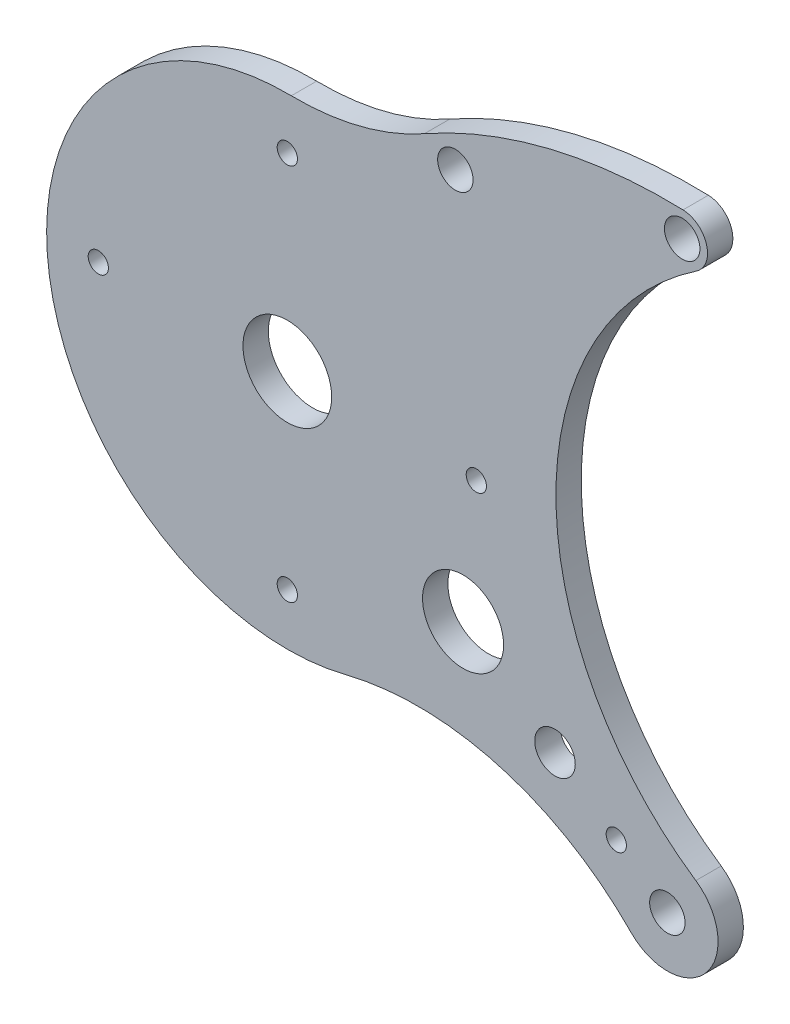
from build123d import *

# Parameters (mm, degrees)
SKETCH1_R           = 7
SKETCH1_R_2         = 4
SKETCH1_R_3         = 17.5
BOSS_EXTRUDE1_DEPTH = 10
SKETCH4_R           = 4
SKETCH4_R_2         = 8
SKETCH4_R_3         = 16
CUT_EXTRUDE1_DEPTH  = 11


with BuildPart() as part:
    # Sketch1 → Boss-Extrude1 (new body)
    with BuildSketch(Plane.XY):
        with BuildLine():
            ThreePointArc((1.572195793, 94.986989637), (-94.380567411, -10.83090463), (23.048944019, -92.161522229))
            ThreePointArc((23.048944019, -92.161522229), (83.617990825, -93.079348945), (135.711425994, -123.994164958))
            ThreePointArc((135.711425994, -123.994164958), (165.350102595, -122.820856068), (161.225161537, -93.447183066))
            ThreePointArc((161.225161537, -93.447183066), (106.014165413, 10.833093568), (161.441107802, 114.998751274))
            ThreePointArc((161.441107802, 114.998751274), (165.454566443, 126.056147345), (156.171848547, 133.281450563))
            ThreePointArc((156.171848547, 133.281450563), (103.433194213, 127.791254655), (54.122076862, 108.299676532))
            ThreePointArc((54.122076862, 108.299676532), (28.73316338, 98.145871106), (1.572195793, 94.986989637))
        make_face()
        with Locations((66.321036094, 102.089205288)):
            Circle(SKETCH1_R, mode=Mode.SUBTRACT)
        with Locations((155.845687485, 123.28677103)):
            Circle(SKETCH1_R, mode=Mode.SUBTRACT)
        with Locations((150, -110)):
            Circle(SKETCH1_R, mode=Mode.SUBTRACT)
        with Locations((0, 74.6)):
            Circle(SKETCH1_R_2, mode=Mode.SUBTRACT)
        with Locations((74.6, 0)):
            Circle(SKETCH1_R_2, mode=Mode.SUBTRACT)
        with Locations((0, -74.6)):
            Circle(SKETCH1_R_2, mode=Mode.SUBTRACT)
        with Locations((-74.6, 0)):
            Circle(SKETCH1_R_2, mode=Mode.SUBTRACT)
        Circle(SKETCH1_R_3, mode=Mode.SUBTRACT)
    extrude(amount=BOSS_EXTRUDE1_DEPTH)

    # Sketch4 → Cut-Extrude1 (cut, through all)
    with BuildSketch(Plane.XY.offset(10)):
        with Locations((129.839875104, -95.215908409)):
            Circle(SKETCH4_R)
        with Locations((105.647725228, -77.4749985)):
            Circle(SKETCH4_R_2)
        with Locations((69.359500414, -50.863633637)):
            Circle(SKETCH4_R_3)
    extrude(amount=-CUT_EXTRUDE1_DEPTH, mode=Mode.SUBTRACT)


solid = part.part
